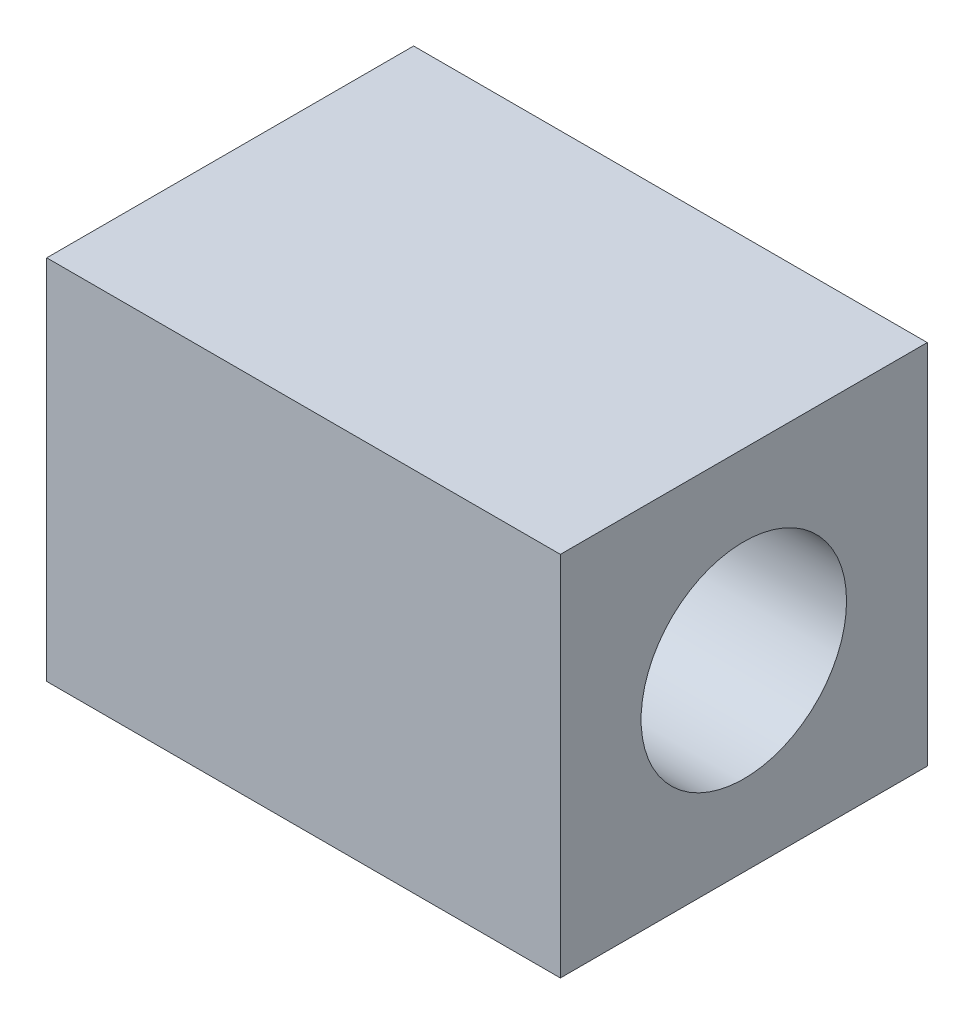
from build123d import *

# Parameters (mm, degrees)
SKETCH1_W           = 31.75
SKETCH1_H           = 31.75
SKETCH1_R           = 8.89
BOSS_EXTRUDE1_DEPTH = 22.225


with BuildPart() as part:
    # Sketch1 → Boss-Extrude1 (new body, symmetric)
    with BuildSketch(Plane(origin=(0, 0, 0), x_dir=(0, 0, -1), z_dir=(1, 0, 0))):
        Rectangle(SKETCH1_W, SKETCH1_H)
        Circle(SKETCH1_R, mode=Mode.SUBTRACT)
    extrude(amount=BOSS_EXTRUDE1_DEPTH, both=True)


solid = part.part
